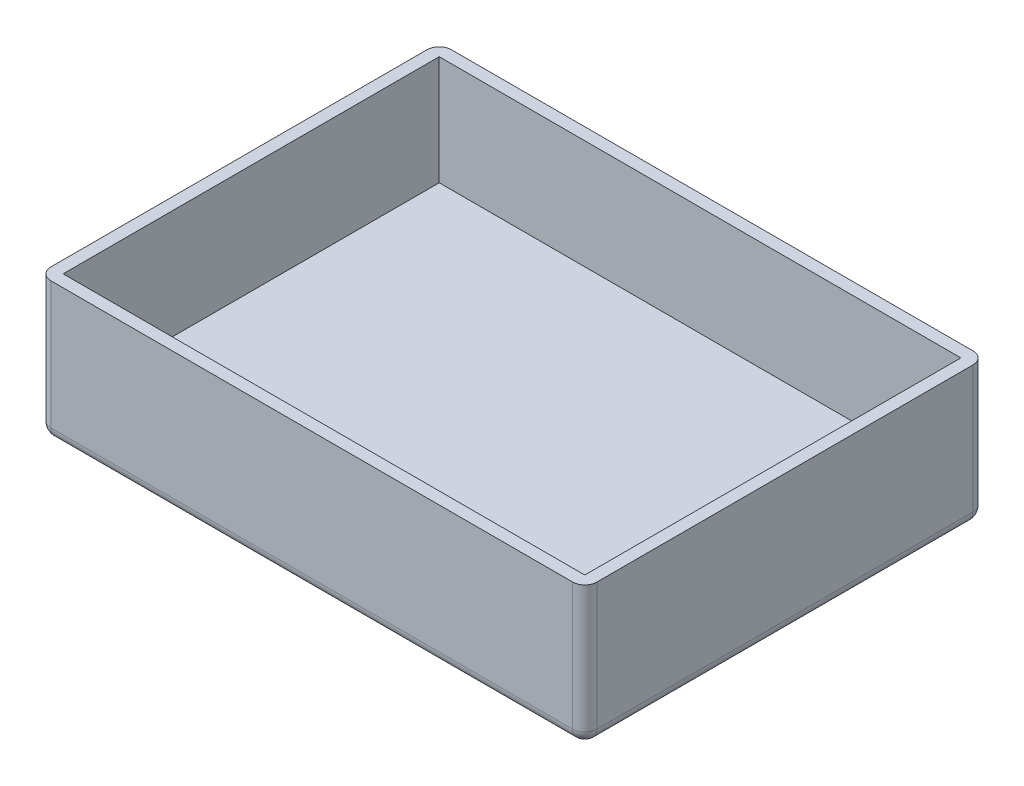
from build123d import *

# Parameters (mm, degrees)
SKETCH1_W           = 450
SKETCH1_H           = 330
BOSS_EXTRUDE1_DEPTH = 115
SKETCH2_W           = 430
SKETCH2_H           = 310
CUT_EXTRUDE1_DEPTH  = 90
FILLET1_R           = 10


with BuildPart() as part:
    # Sketch1 → Boss-Extrude1 (new body)
    with BuildSketch(Plane(origin=(0, 0, 0), x_dir=(1, 0, 0), z_dir=(0, 1, 0))):
        with Locations((162.172357903, 131.565585437)):
            Rectangle(SKETCH1_W, SKETCH1_H)
    extrude(amount=BOSS_EXTRUDE1_DEPTH)

    # Sketch2 → Cut-Extrude1 (cut)
    with BuildSketch(Plane(origin=(0, 115, 0), x_dir=(1, 0, 0), z_dir=(0, 1, 0))):
        with Locations((162.172357903, 131.565585437)):
            Rectangle(SKETCH2_W, SKETCH2_H)
    extrude(amount=-CUT_EXTRUDE1_DEPTH, mode=Mode.SUBTRACT)

    # Fillet1
    fillet1_edges = [part.edges().sort_by_distance(p)[0] for p in [
        (162.172357903, 0, -296.565585437),
        (387.172357903, 0, -131.565585437),
        (162.172357903, 0, 33.434414563),
        (-62.827642097, 0, -131.565585437),
        (-62.827642097, 57.5, -296.565585437),
        (387.172357903, 57.5, -296.565585437),
        (387.172357903, 57.5, 33.434414563),
        (-62.827642097, 57.5, 33.434414563),
    ]]
    fillet(fillet1_edges, radius=FILLET1_R)


solid = part.part
